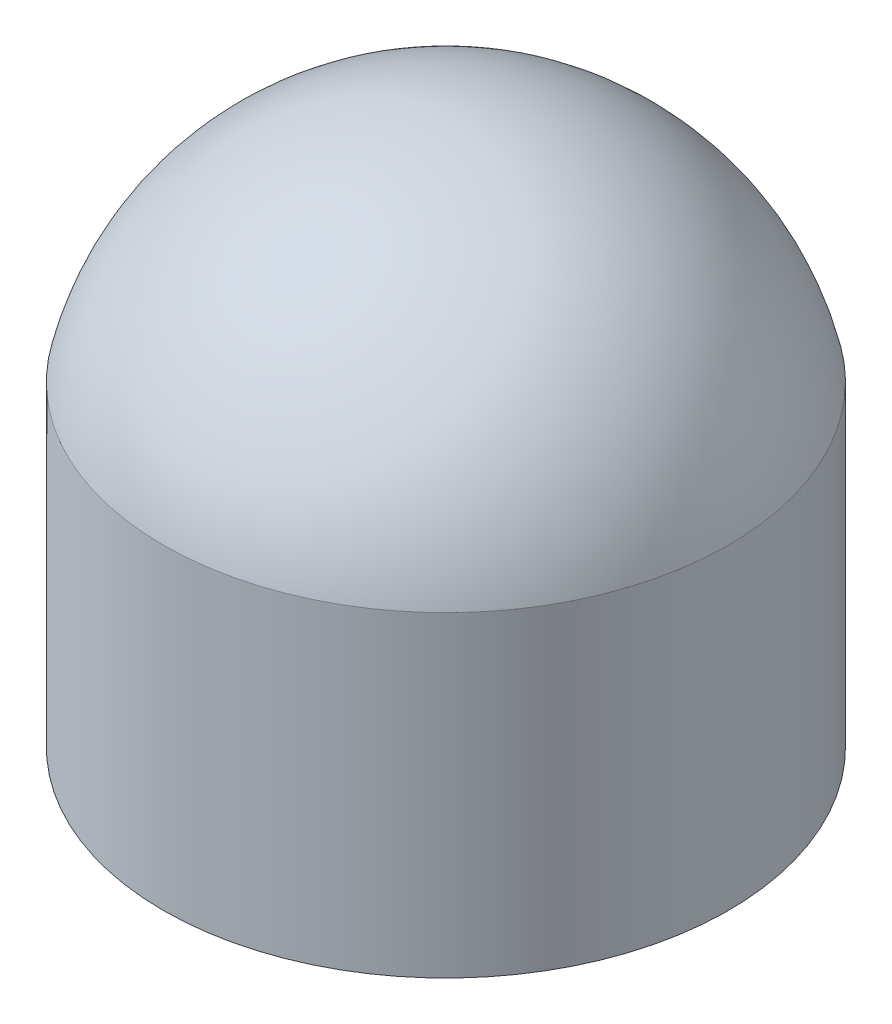
from build123d import *

# Parameters (mm, degrees)
SKETCH1_R           = 1.25
BOSS_EXTRUDE1_DEPTH = 1.4
DOME1_FACE_RADIUS   = 1.25
DOME1_HEIGHT        = 1


with BuildPart() as part:
    # Sketch1 → Boss-Extrude1 (new body)
    with BuildSketch(Plane(origin=(0, 0, 0), x_dir=(1, 0, 0), z_dir=(0, 1, 0))):
        Circle(SKETCH1_R)
    extrude(amount=BOSS_EXTRUDE1_DEPTH)

    # Dome1: a dome of height H over a round flat face of radius A is a cap of a sphere of radius (A * A + H * H) / (2 * H)
    dome1_r = (DOME1_FACE_RADIUS * DOME1_FACE_RADIUS + DOME1_HEIGHT * DOME1_HEIGHT) / (2 * DOME1_HEIGHT)
    dome1_base = Plane((0, 1.4, 0), z_dir=(0, 1, 0))
    with Locations(dome1_base.offset(DOME1_HEIGHT - dome1_r)):
        dome1_ball = Sphere(dome1_r, mode=Mode.PRIVATE)
    add(split(dome1_ball, bisect_by=dome1_base, keep=Keep.TOP, mode=Mode.PRIVATE))


solid = part.part
